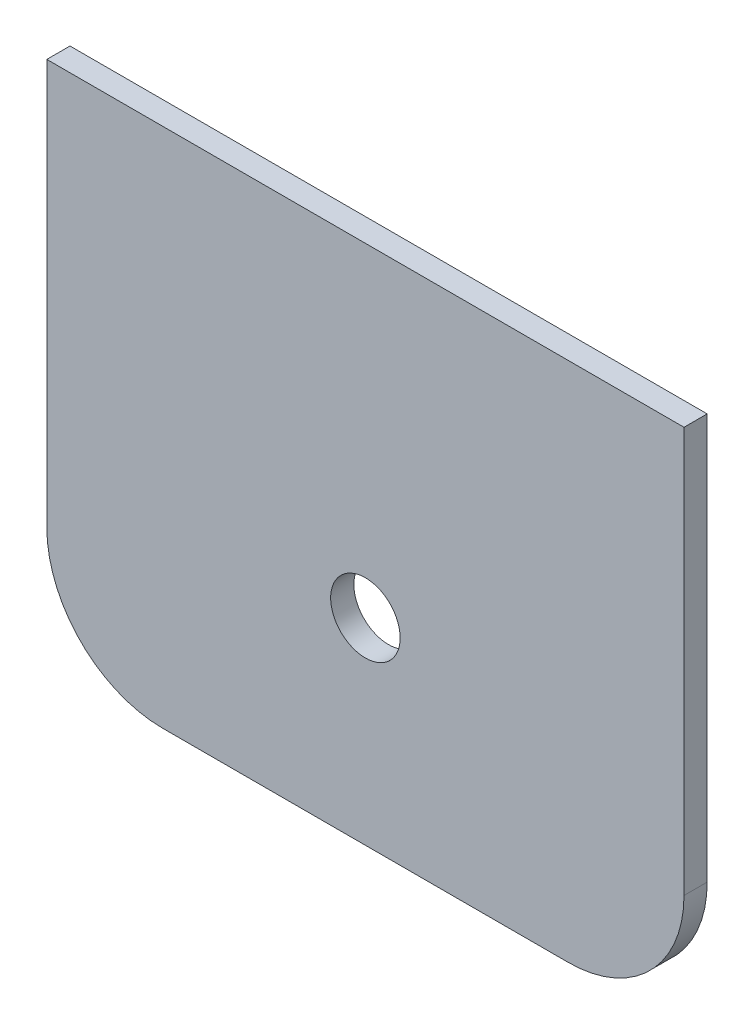
from build123d import *

# Parameters (mm, degrees)
SZKIC1_W                    = 55
SZKIC1_H                    = 45
DODANIE_WYCI_GNI_CIE1_DEPTH = 2
ZAOKR_GLENIE1_R             = 10
ZAOKR_GLENIE2_R             = 10
SZKIC2_R                    = 3
WYTNIJ_WYCI_GNI_CIE2_DEPTH  = 2


with BuildPart() as part:
    # Szkic1 → Dodanie-wyciągnięcie1 (new body)
    with BuildSketch(Plane.XY):
        with Locations((0, 721.92245047)):
            Rectangle(SZKIC1_W, SZKIC1_H)
    extrude(amount=DODANIE_WYCI_GNI_CIE1_DEPTH)

    # Zaokrąglenie1
    zaokr_glenie1_edges = [part.edges().sort_by_distance(p)[0] for p in [
        (-27.5, 699.42245047, 1),
    ]]
    fillet(zaokr_glenie1_edges, radius=ZAOKR_GLENIE1_R)

    # Zaokrąglenie2
    zaokr_glenie2_edges = [part.edges().sort_by_distance(p)[0] for p in [
        (27.5, 699.42245047, 1),
    ]]
    fillet(zaokr_glenie2_edges, radius=ZAOKR_GLENIE2_R)

    # Szkic2 → Wytnij-wyciągnięcie2 (cut)
    with BuildSketch(Plane.XY.offset(2)):
        with Locations((0, 716.42245047)):
            Circle(SZKIC2_R)
    extrude(amount=-WYTNIJ_WYCI_GNI_CIE2_DEPTH, mode=Mode.SUBTRACT)


solid = part.part
